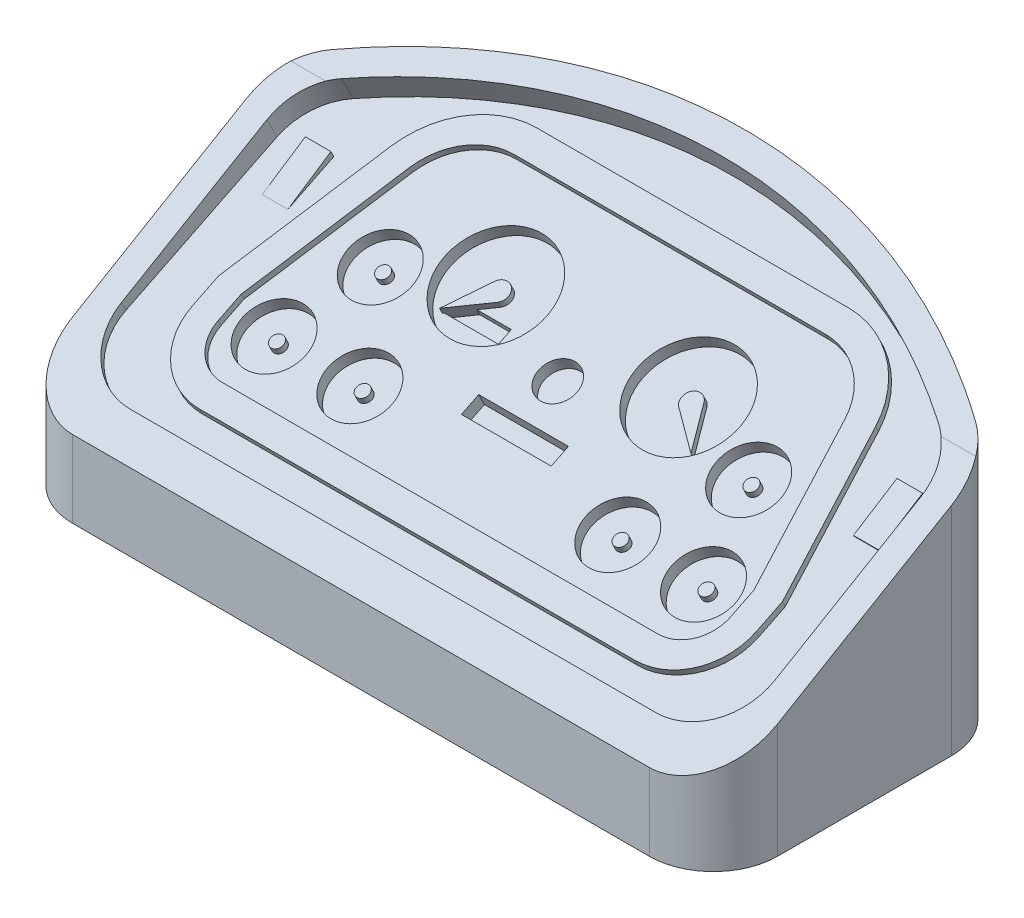
from build123d import *

# Parameters (mm, degrees)
BOSS_EXTRUDE1_DEPTH = 25
CUT_EXTRUDE1_DEPTH  = 56
CUT_EXTRUDE2_DEPTH  = 2
CUT_EXTRUDE3_DEPTH  = 56.0000001
BOSS_EXTRUDE2_DEPTH = 0.5
FILLET2_R           = 5
FILLET4_R           = 5
FILLET5_R           = 5
SKETCH6_R           = 4
SKETCH6_R_2         = 2.5
SKETCH6_R_3         = 1.5
SKETCH6_W           = 7
SKETCH6_H           = 1.501556971
CUT_EXTRUDE4_DEPTH  = 1
BOSS_EXTRUDE3_DEPTH = 0.5
SKETCH8_R           = 0.5
BOSS_EXTRUDE4_DEPTH = 0.5
CUT_EXTRUDE5_DEPTH  = 0.5
SKETCH10_W          = 2
SKETCH10_H          = 4
BOSS_EXTRUDE5_DEPTH = 0.5
CUT_EXTRUDE6_DEPTH  = 2
CUT_EXTRUDE7_DEPTH  = 2


with BuildPart() as part:
    # Sketch1 → Boss-Extrude1 (new body)
    with BuildSketch(Plane(origin=(0, 0, 0), x_dir=(1, 0, 0), z_dir=(0, 1, 0))):
        with BuildLine():
            Line((-27.5, 6.25), (-27.5, -15))
            Line((-27.5, -15), (27.5, -15))
            Line((27.5, -15), (27.5, 6.25))
            ThreePointArc((27.5, 6.25), (0, 15), (-27.5, 6.25))
        make_face()
    extrude(amount=BOSS_EXTRUDE1_DEPTH)

    # Sketch2 → Cut-Extrude1 (cut, through all)
    with BuildSketch(Plane(origin=(27.5, 0, 0), x_dir=(0, 0, -1), z_dir=(1, 0, 0))):
        Polygon((-15, 8), (15, 22.824529963), (15, 25), (-15, 25), align=None)
    extrude(amount=-CUT_EXTRUDE1_DEPTH, mode=Mode.SUBTRACT)

    # Sketch3 → Cut-Extrude2 (cut)
    with BuildSketch(Plane(origin=(0, 12.387436262, 6.121264001), x_dir=(1, 0, 0), z_dir=(0, 0.89651484, 0.443013704))):
        with BuildLine():
            Line((-25.5, 10.23830007), (-25.5, -7.903612972))
            Line((-25.5, -7.903612972), (25.5, -7.903612972))
            Line((25.5, -7.903612972), (25.5, 10.238296947))
            ThreePointArc((25.5, 10.238296947), (24.907293379, 12.599602744), (23.269693973, 14.40108391))
            add(Edge.make_bspline(
                [(23.269693973, 14.40108391), (22.122214348, 15.164554976), (20.94493023, 15.871336285), (17.734831315, 17.599553604), (15.649676942, 18.521436915), (12.93284925, 19.463833346), (12.383197637, 19.641920344), (11.282858983, 19.973451503), (10.731016127, 20.127331411), (9.070515859, 20.553661297), (7.956893593, 20.790850084), (4.596297841, 21.362298201), (2.329710672, 21.557257961), (-1.110917839, 21.560300401), (-2.268023373, 21.512162029), (-4.552325625, 21.320060503), (-5.684502339, 21.176395804), (-9.051900597, 20.606337494), (-11.258147255, 20.041629121), (-14.509660741, 18.918382275), (-15.58692593, 18.496052007), (-17.688755449, 17.572497213), (-18.716963562, 17.07031031), (-20.937080939, 15.876150048), (-22.119122989, 15.166616669), (-23.269698352, 14.40108412)],
                knots=[0.04966081, 0.04966081, 0.04966081, 0.04966081, 0.125, 0.125, 0.25, 0.25, 0.28125, 0.28125, 0.3125, 0.3125, 0.375, 0.375, 0.5, 0.5, 0.5625, 0.5625, 0.625, 0.625, 0.75, 0.75, 0.8125, 0.8125, 0.875, 0.875, 0.950394251, 0.950394251, 0.950394251, 0.950394251], degree=3))
            ThreePointArc((-23.269698352, 14.40108412), (-24.907294621, 12.599603549), (-25.5, 10.23830007))
        make_face()
    extrude(amount=-CUT_EXTRUDE2_DEPTH, mode=Mode.SUBTRACT)

    # Sketch4 → Cut-Extrude3 (cut, through all)
    with BuildSketch(Plane(origin=(27.5, 0, 0), x_dir=(0, 0, -1), z_dir=(1, 0, 0))):
        Polygon((-15, 8), (-15, 6), (6.25, 18.500708724), align=None)
    extrude(amount=-CUT_EXTRUDE3_DEPTH, mode=Mode.SUBTRACT)

    # Sketch5 → Boss-Extrude2 (add)
    with BuildSketch(Plane(origin=(0, 10.594406582, 5.235236594), x_dir=(1, 0, 0), z_dir=(0, 0.89651484, 0.443013704))):
        with BuildLine():
            Line((-21.874738248, 1.358474377), (-21.874738248, -0.903612972))
            ThreePointArc((-21.874738248, -0.903612972), (-20.410272153, -4.439146877), (-16.874738248, -5.903612972))
            Line((-16.874738248, -5.903612972), (17.125261752, -5.903612972))
            ThreePointArc((17.125261752, -5.903612972), (20.660795658, -4.439146877), (22.125261752, -0.903612972))
            Line((22.125261752, -0.903612972), (22.125261752, 1.358474377))
            Line((22.125261752, 1.358474377), (19.047514764, 12.900025582))
            ThreePointArc((19.047514764, 12.900025582), (16.54852317, 16.647309018), (12.283870187, 18.096387028))
            Line((12.283870187, 18.096387028), (-12.033346682, 18.096387028))
            ThreePointArc((-12.033346682, 18.096387028), (-16.297999665, 16.647309018), (-18.796991259, 12.900025582))
            Line((-18.796991259, 12.900025582), (-21.874738248, 1.358474377))
        make_face()
        with BuildLine():
            Line((-16.874738248, -3.903612972), (17.125261752, -3.903612972))
            ThreePointArc((17.125261752, -3.903612972), (19.246582096, -3.024933315), (20.125261752, -0.903612972))
            Line((20.125261752, -0.903612972), (20.125261752, 1.096387028))
            Line((20.125261752, 1.096387028), (17.115044885, 12.384700281))
            ThreePointArc((17.115044885, 12.384700281), (15.330050889, 15.061331307), (12.283870187, 16.096387028))
            Line((12.283870187, 16.096387028), (-12.033346682, 16.096387028))
            ThreePointArc((-12.033346682, 16.096387028), (-15.079527384, 15.061331307), (-16.86452138, 12.384700281))
            Line((-16.86452138, 12.384700281), (-19.874738248, 1.096387028))
            Line((-19.874738248, 1.096387028), (-19.874738248, -0.903612972))
            ThreePointArc((-19.874738248, -0.903612972), (-18.996058591, -3.024933315), (-16.874738248, -3.903612972))
        make_face(mode=Mode.SUBTRACT)
    extrude(amount=BOSS_EXTRUDE2_DEPTH)

    # Fillet2
    fillet2_edges = [part.edges().sort_by_distance(p)[0] for p in [
        (-27.5, 9.250354362, -6.25),
        (27.5, 9.250354362, -6.25),
    ]]
    fillet(fillet2_edges, radius=FILLET2_R)

    # Fillet4
    fillet4_edges = [part.edges().sort_by_distance(p)[0] for p in [
        (27.5, 3, 15),
        (-27.5, 3, 15),
    ]]
    fillet(fillet4_edges, radius=FILLET4_R)

    # Fillet5
    fillet5_edges = [part.edges().sort_by_distance(p)[0] for p in [
        (25.5, 7.280109363, 12.413404314),
        (-25.5, 7.280109363, 12.413404314),
    ]]
    fillet(fillet5_edges, radius=FILLET5_R)

    # Sketch6 → Cut-Extrude4 (cut)
    with BuildSketch(Plane(origin=(0, 10.594406582, 5.235236594), x_dir=(1, 0, 0), z_dir=(0, 0.89651484, 0.443013704))):
        with Locations((-7.391955117, 9.096387028)):
            Circle(SKETCH6_R)
        with Locations((7.642478622, 9.096387028)):
            Circle(SKETCH6_R)
        with Locations((-14.246179645, 6.679307091)):
            Circle(SKETCH6_R_2)
        with Locations((-16.626340028, 0.096387028)):
            Circle(SKETCH6_R_2)
        with Locations((-9.933747273, 0.096387028)):
            Circle(SKETCH6_R_2)
        with Locations((10.184270778, 0.096387028)):
            Circle(SKETCH6_R_2)
        with Locations((16.876863533, 0.096387028)):
            Circle(SKETCH6_R_2)
        with Locations((14.49670315, 6.679307091)):
            Circle(SKETCH6_R_2)
        with Locations((0.125261752, 6.096387028)):
            Circle(SKETCH6_R_3)
        with Locations((0.125261752, 2.372758697)):
            Rectangle(SKETCH6_W, SKETCH6_H)
    extrude(amount=-CUT_EXTRUDE4_DEPTH, mode=Mode.SUBTRACT)

    # Sketch7 → Boss-Extrude3 (add)
    with BuildSketch(Plane(origin=(0, 9.697891742, 4.79222289), x_dir=(1, 0, 0), z_dir=(0, 0.89651484, 0.443013704))):
        with BuildLine():
            Line((-8.048414678, 9.459100199), (-9.681837773, 6.502835312))
            Line((-9.681837773, 6.502835312), (-6.950708776, 8.489920486))
            ThreePointArc((-6.950708776, 8.489920486), (-6.895561612, 9.65860895), (-8.048414678, 9.459100199))
        make_face()
        with BuildLine():
            Line((8.298938183, 9.459100199), (9.932361278, 6.502835312))
            Line((9.932361278, 6.502835312), (7.201232281, 8.489920486))
            ThreePointArc((7.201232281, 8.489920486), (7.146085117, 9.65860895), (8.298938183, 9.459100199))
        make_face()
    extrude(amount=BOSS_EXTRUDE3_DEPTH)

    # Sketch8 → Boss-Extrude4 (add)
    with BuildSketch(Plane(origin=(0, 9.697891742, 4.79222289), x_dir=(1, 0, 0), z_dir=(0, 0.89651484, 0.443013704))):
        with Locations((-14.246179645, 6.679307091)):
            Circle(SKETCH8_R)
        with Locations((-16.626340028, 0.096387028)):
            Circle(SKETCH8_R)
        with Locations((-9.933747273, 0.096387028)):
            Circle(SKETCH8_R)
        with Locations((14.49670315, 6.679307091)):
            Circle(SKETCH8_R)
        with Locations((10.184270778, 0.096387028)):
            Circle(SKETCH8_R)
        with Locations((16.876863533, 0.096387028)):
            Circle(SKETCH8_R)
    extrude(amount=BOSS_EXTRUDE4_DEPTH)

    # Sketch9 → Cut-Extrude5 (cut)
    with BuildSketch(Plane(origin=(0, 9.697891742, 4.79222289), x_dir=(1, 0, 0), z_dir=(0, 0.89651484, 0.443013704))):
        Polygon((-9.58567888, 6.572797555), (-8.049200513, 7.690691798), (-5.371486784, 7.690691798), (-5.371486784, 6.572797555), align=None)
    extrude(amount=-CUT_EXTRUDE5_DEPTH, mode=Mode.SUBTRACT)

    # Sketch10 → Boss-Extrude5 (add)
    with BuildSketch(Plane(origin=(0, 10.594406582, 5.235236594), x_dir=(1, 0, 0), z_dir=(0, 0.89651484, 0.443013704))):
        with Locations((-22.660381166, 8.906356756)):
            Rectangle(SKETCH10_W, SKETCH10_H)
        with Locations((23.5, 8.906356756)):
            Rectangle(SKETCH10_W, SKETCH10_H)
    extrude(amount=BOSS_EXTRUDE5_DEPTH)

    # Sketch11 → Cut-Extrude6 (cut)
    with BuildSketch(Plane.ZY.offset(-22.5)):
        Polygon((-4.320967236, 15.874329501), (-0.923579886, 13.720464249), (-0.734907876, 14.102274687), align=None)
    extrude(amount=-CUT_EXTRUDE6_DEPTH, mode=Mode.SUBTRACT)

    # Sketch12 → Cut-Extrude7 (cut)
    with BuildSketch(Plane.ZY.offset(23.660381166)):
        Polygon((-4.320967236, 15.874329501), (-0.956414728, 13.654017267), (-0.734907876, 14.102274687), align=None)
    extrude(amount=-CUT_EXTRUDE7_DEPTH, mode=Mode.SUBTRACT)


solid = part.part
